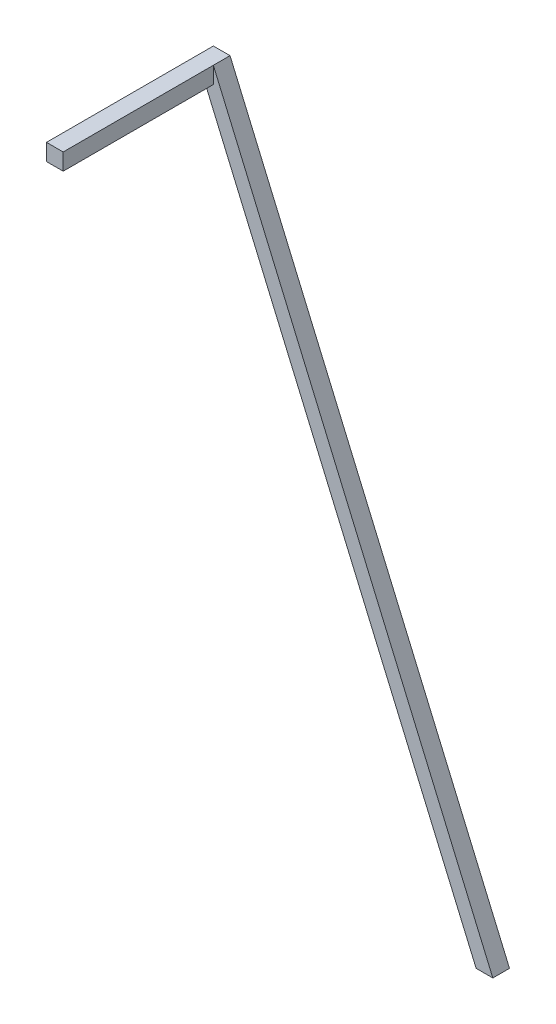
from build123d import *

# Parameters (mm, degrees)
SKETCH1_W           = 25.4
SKETCH1_H           = 25.4
BOSS_EXTRUDE1_DEPTH = 254
BOSS_EXTRUDE2_DEPTH = 25.4


with BuildPart() as part:
    # Sketch1 → Boss-Extrude1 (new body)
    with BuildSketch(Plane.XY):
        Rectangle(SKETCH1_W, SKETCH1_H)
    extrude(amount=BOSS_EXTRUDE1_DEPTH)


with BuildPart() as body_2:
    # Sketch2 → Boss-Extrude2 (new body)
    with BuildSketch(Plane.XY):
        Polygon((12.7, 12.7), (438.15, -977.9), (412.75, -977.9), (-1.791025641, -12.7), (12.7, -12.7), align=None)
    extrude(amount=BOSS_EXTRUDE2_DEPTH)


solid = Compound([part.part, body_2.part])
